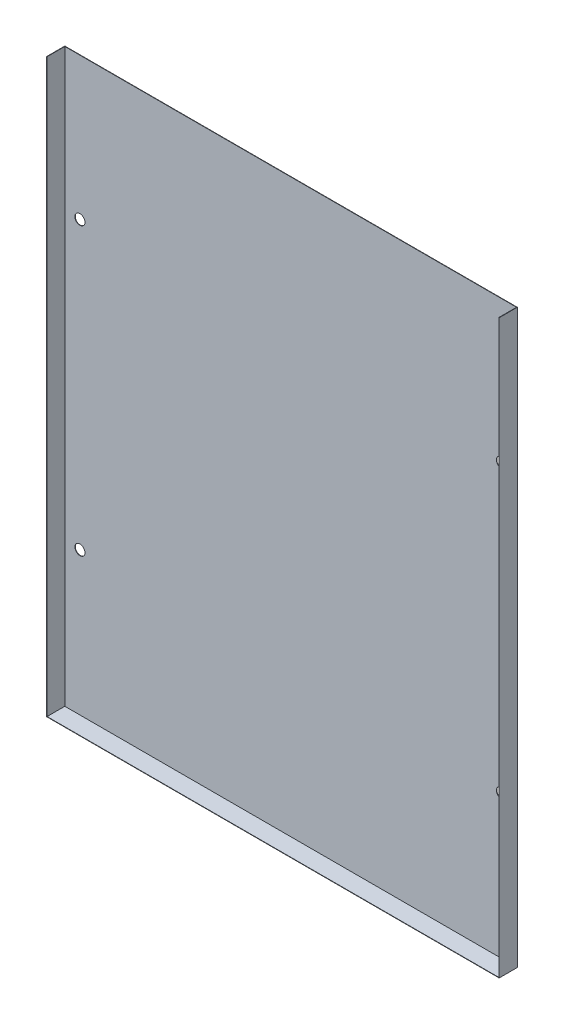
from build123d import *

# Parameters (mm, degrees)
SKETCH1_W            = 89.72
SKETCH1_H            = 227
SKETCH1_R            = 2
HEAT_EXCHANGER_DEPTH = 0.1524
CONVECTION_FIN_DEPTH = 7.2048


with BuildPart() as part:
    # Sketch1 → Heat Exchanger (new body)
    with BuildSketch(Plane.XY):
        with Locations((-44.86, 0)):
            Rectangle(SKETCH1_W, SKETCH1_H)
        with Locations((-83.72, -56.6738)):
            Circle(SKETCH1_R, mode=Mode.SUBTRACT)
        with Locations((-83.72, 56.9786)):
            Circle(SKETCH1_R, mode=Mode.SUBTRACT)
    heat_exchanger = extrude(amount=HEAT_EXCHANGER_DEPTH)

    # Sketch3 → Convection Fin (add)
    with BuildSketch(Plane.XY):
        Polygon((0, -113.6524), (0, -113.5), (-89.72, -113.5), (-89.72, 113.5), (-89.8724, 113.5), (-89.8724, -113.6524), align=None)
    convection_fin = extrude(amount=CONVECTION_FIN_DEPTH)

    # Mirror1: Heat Exchanger, Convection Fin across plane
    add(heat_exchanger.mirror(Plane(origin=(0, 0, 0), x_dir=(0, 0, 1), z_dir=(1, 0, 0))))
    add(convection_fin.mirror(Plane(origin=(0, 0, 0), x_dir=(0, 0, 1), z_dir=(1, 0, 0))))


solid = part.part
